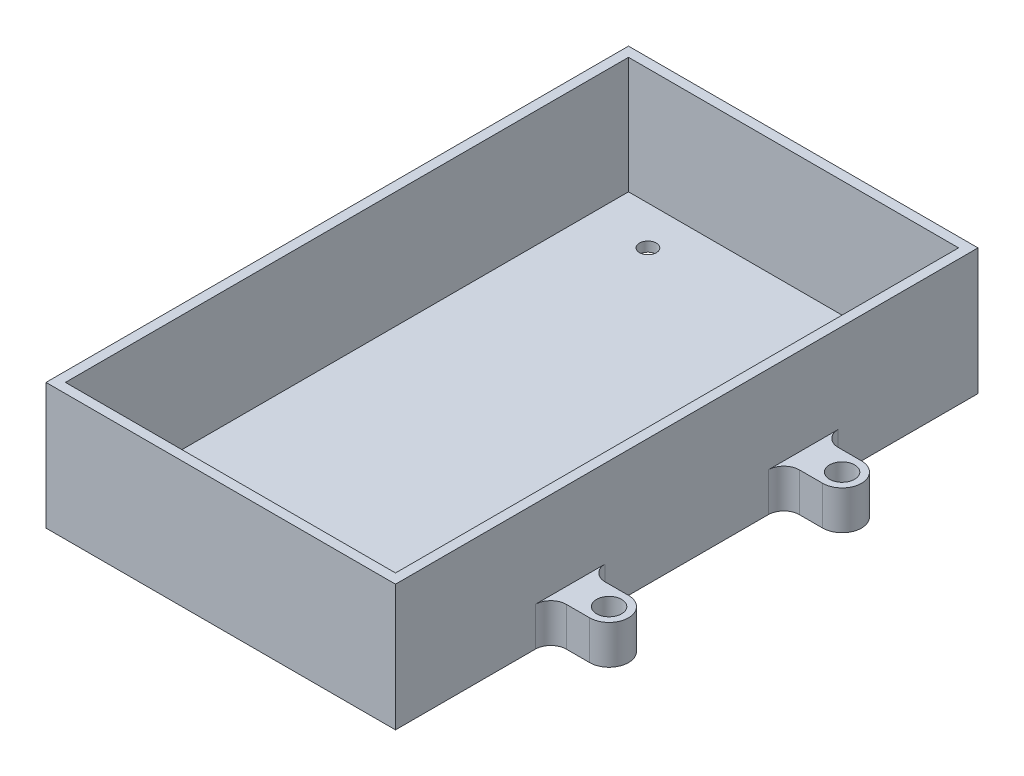
from build123d import *

# Parameters (mm, degrees)
SKETCH1_W           = 57.15
SKETCH1_H           = 95.25
SKETCH1_R           = 1.375
BOSS_EXTRUDE1_DEPTH = 1.5875
SKETCH1_3_W         = 57.15
SKETCH1_3_H         = 95.25
BOSS_EXTRUDE2_DEPTH = 19.05
SKETCH3_R           = 2.05
BOSS_EXTRUDE5_DEPTH = 6.35
FILLET1_R           = 2.54


with BuildPart() as part:
    # Sketch1 → Boss-Extrude1 (new body)
    with BuildSketch(Plane(origin=(0, 0, 0), x_dir=(1, 0, 0), z_dir=(0, 1, 0))):
        Rectangle(SKETCH1_W, SKETCH1_H)
        with Locations((-17.4625, -39.6875)):
            Circle(SKETCH1_R, mode=Mode.SUBTRACT)
        with Locations((17.4625, -39.6875)):
            Circle(SKETCH1_R, mode=Mode.SUBTRACT)
        with Locations((-17.4625, 39.6875)):
            Circle(SKETCH1_R, mode=Mode.SUBTRACT)
        with Locations((17.4625, 39.6875)):
            Circle(SKETCH1_R, mode=Mode.SUBTRACT)
    extrude(amount=-BOSS_EXTRUDE1_DEPTH)

    # Sketch1_3 → Boss-Extrude2 (add)
    with BuildSketch(Plane(origin=(0, 0, 0), x_dir=(1, 0, 0), z_dir=(0, 1, 0))):
        Rectangle(SKETCH1_3_W, SKETCH1_3_H)
        Polygon((26.9875, 0), (26.9875, -46.0375), (-26.9875, -46.0375), (-26.9875, 46.0375), (26.9875, 46.0375), align=None, mode=Mode.SUBTRACT)
    extrude(amount=BOSS_EXTRUDE2_DEPTH)

    # Sketch3 → Boss-Extrude5 (add)
    # profile 1 of 2: a face of its own
    with BuildSketch(Plane.XZ.offset(1.5875)):
        with BuildLine():
            Line((28.575, 15.875), (34.925, 15.875))
            ThreePointArc((34.925, 15.875), (38.1, 19.05), (34.925, 22.225))
            Line((34.925, 22.225), (28.575, 22.225))
            Line((28.575, 22.225), (28.575, 15.875))
        make_face()
        with Locations((34.925, 19.05)):
            Circle(SKETCH3_R, mode=Mode.SUBTRACT)
    # profile 2 of 2: a face of its own
    with BuildSketch(Plane.XZ.offset(1.5875)):
        with BuildLine():
            Line((34.925, -15.875), (28.575, -15.875))
            Line((28.575, -15.875), (28.575, -22.225))
            Line((28.575, -22.225), (34.925, -22.225))
            ThreePointArc((34.925, -22.225), (38.1, -19.05), (34.925, -15.875))
        make_face()
        with Locations((34.925, -19.05)):
            Circle(SKETCH3_R, mode=Mode.SUBTRACT)
    extrude(amount=-BOSS_EXTRUDE5_DEPTH)

    # Fillet1
    fillet1_edges = [part.edges().sort_by_distance(p)[0] for p in [
        (28.575, 1.5875, -22.225),
        (28.575, 1.5875, -15.875),
        (28.575, 1.5875, 15.875),
        (28.575, 1.5875, 22.225),
    ]]
    fillet(fillet1_edges, radius=FILLET1_R)


solid = part.part
